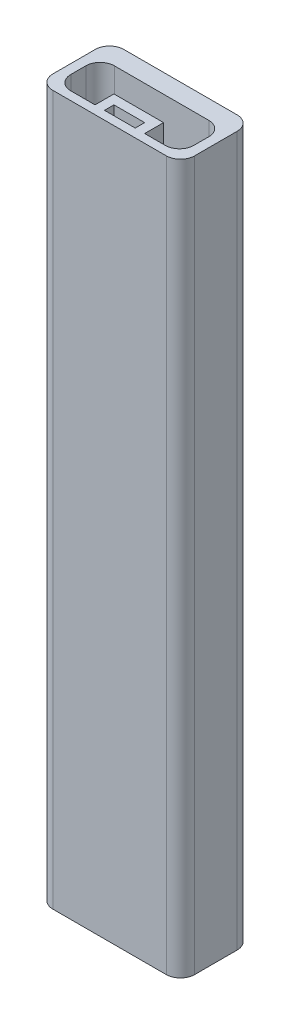
from build123d import *

# Parameters (mm, degrees)
SKETCH2_W           = 30
SKETCH2_H           = 15
SKETCH2_W_2         = 26
SKETCH2_H_2         = 9.2
BOSS_EXTRUDE1_DEPTH = 150
BOSS_EXTRUDE2_DEPTH = 5
FILLET1_R           = 3
LPATTERN1_COUNT     = 15
LPATTERN1_PITCH     = 10


with BuildPart() as part:
    # Sketch2 → Boss-Extrude1 (new body)
    with BuildSketch(Plane(origin=(0, 0, 0), x_dir=(1, 0, 0), z_dir=(0, 1, 0))):
        Rectangle(SKETCH2_W, SKETCH2_H)
        with Locations((0, -1.1)):
            Rectangle(SKETCH2_W_2, SKETCH2_H_2, mode=Mode.SUBTRACT)
    extrude(amount=BOSS_EXTRUDE1_DEPTH)

    # Sketch3 → Boss-Extrude2 (add)
    with BuildSketch(Plane(origin=(0, 150, 0), x_dir=(1, 0, 0), z_dir=(0, 1, 0))):
        Polygon((-2.87163554, -5.7), (-2.87163554, -3.7), (3.631457211, -3.7), (3.631457211, -5.7), (5.631457211, -5.7), (5.631457211, -1.7), (-4.87163554, -1.7), (-4.87163554, -5.7), align=None)
    boss_extrude2 = extrude(amount=-BOSS_EXTRUDE2_DEPTH)

    # Fillet1
    fillet1_edges = [part.edges().sort_by_distance(p)[0] for p in [
        (-13, 75, -3.5),
        (-13, 75, 5.7),
        (13, 75, 5.7),
        (13, 75, -3.5),
        (-15, 75, -7.5),
        (15, 75, -7.5),
        (15, 75, 7.5),
        (-15, 75, 7.5),
    ]]
    fillet(fillet1_edges, radius=FILLET1_R)

    # LPattern1: Boss-Extrude2 ×15
    with Locations(*[(0, -i * LPATTERN1_PITCH, 0) for i in range(1, LPATTERN1_COUNT)]):
        add(boss_extrude2)


solid = part.part
